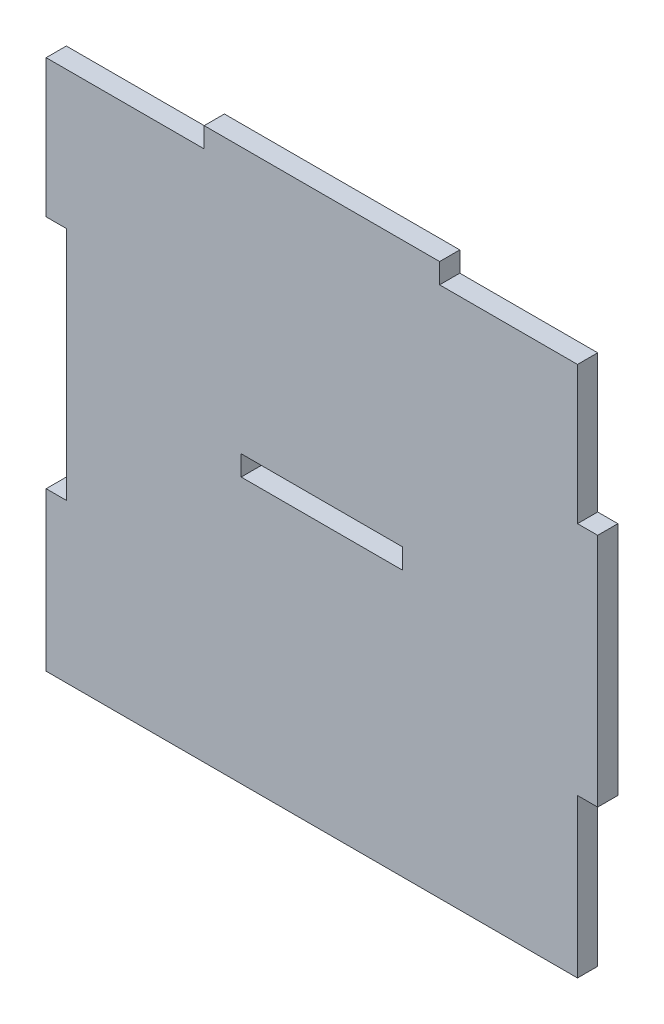
from build123d import *

# Parameters (mm, degrees)
BOSS_EXTRUDE1_DEPTH = 3
SKETCH2_W           = 24
SKETCH2_H           = 3
CUT_EXTRUDE1_DEPTH  = 3


with BuildPart() as part:
    # Sketch1 → Boss-Extrude1 (new body)
    with BuildSketch(Plane.XY):
        Polygon((-38, 39.5), (-17.5, 39.5), (-17.5, 42.5), (17.5, 42.5), (17.5, 39.5), (38, 39.5), (38, 19), (41, 19), (41, 16), (41, -16), (38, -16), (38, -19), (38, -39.5), (-41, -39.5), (-41, -19), (-41, -16), (-38, -16), (-38, 16), (-38, 19), (-41, 19), (-41, 39.5), align=None)
    extrude(amount=BOSS_EXTRUDE1_DEPTH)

    # Sketch2 → Cut-Extrude1 (cut)
    with BuildSketch(Plane.XY.offset(3)):
        with Locations((0, 1.5)):
            Rectangle(SKETCH2_W, SKETCH2_H)
    extrude(amount=-CUT_EXTRUDE1_DEPTH, mode=Mode.SUBTRACT)


solid = part.part
